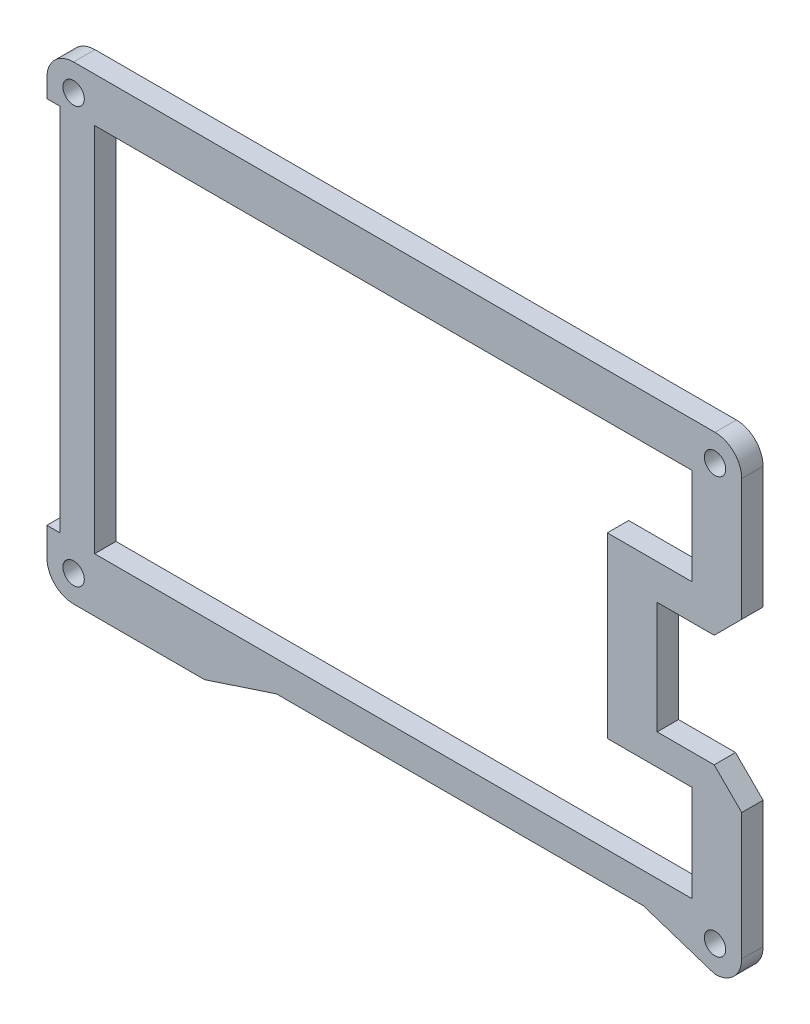
from build123d import *

# Parameters (mm, degrees)
BOSS_EXTRUDE1_DEPTH = 3.048
SKETCH2_R           = 1.355900406
CUT_EXTRUDE1_DEPTH  = 4.048
SKETCH3_R           = 1.524
CUT_EXTRUDE2_DEPTH  = 4.048
CUT_EXTRUDE3_DEPTH  = 4.048
BOSS_EXTRUDE2_DEPTH = 3.048
SKETCH5_W           = 73.1256
SKETCH5_H           = 52.8987
SKETCH5_W_2         = 9.017
SKETCH5_H_2         = 13.74935
CUT_EXTRUDE4_DEPTH  = 4.048
SKETCH6_W           = 3.048
SKETCH6_H           = 13.74935
CUT_EXTRUDE5_DEPTH  = 4.048


with BuildPart() as part:
    # Sketch1 → Boss-Extrude1 (new body)
    with BuildSketch(Plane.XY):
        with BuildLine():
            Line((-309.8086, 128.8851), (-305.87795, 128.8851))
            Line((-305.87795, 128.8851), (-301.9473, 132.81575))
            Line((-301.9473, 132.81575), (-301.9473, 150.9704))
            ThreePointArc((-301.9473, 150.9704), (-303.063223164, 153.664476836), (-305.7573, 154.7804))
            Line((-305.7573, 154.7804), (-397.247125, 154.7804))
            ThreePointArc((-397.247125, 154.7804), (-399.946077222, 153.659592612), (-401.0571, 150.956597849))
            Line((-401.0571, 150.956597849), (-401.0571, 148.341))
            Line((-401.0571, 148.341), (-399.1521, 148.341))
            Line((-399.1521, 148.341), (-399.1521, 95.6449))
            Line((-399.1521, 95.6449), (-401.0571, 95.6449))
            Line((-401.0571, 95.6449), (-401.0571, 91.659304166))
            ThreePointArc((-401.0571, 91.659304166), (-399.951018769, 88.947400452), (-397.2472, 87.8217))
            Line((-397.2472, 87.8217), (-378.5565, 87.8217))
            Line((-378.5565, 87.8217), (-368.3165, 91.1883))
            Line((-368.3165, 91.1883), (-315.9973, 91.1883))
            Line((-315.9973, 91.1883), (-305.7573, 87.8217))
            ThreePointArc((-305.7573, 87.8217), (-303.063223164, 88.937623164), (-301.9473, 91.6317))
            Line((-301.9473, 91.6317), (-301.9473, 111.74645))
            Line((-301.9473, 111.74645), (-305.87795, 115.6771))
            Line((-305.87795, 115.6771), (-309.8086, 115.6771))
            Line((-309.8086, 115.6771), (-314.0123, 115.6771))
            Line((-314.0123, 115.6771), (-314.0123, 128.8851))
            Line((-314.0123, 128.8851), (-309.8086, 128.8851))
        make_face()
        Polygon((-395.3675, 92.9525), (-395.3675, 149.2432), (-309.8086, 149.2432), (-309.8086, 132.81575), (-318.2033, 132.81575), (-318.2033, 111.74645), (-309.8086, 111.74645), (-309.8086, 92.9525), align=None, mode=Mode.SUBTRACT)
    extrude(amount=BOSS_EXTRUDE1_DEPTH)

    # Sketch2 → Cut-Extrude1 (cut, through all)
    with BuildSketch(Plane(origin=(0, 0, 0), x_dir=(-1, 0, 0), z_dir=(0, 0, -1))):
        with Locations((305.7573, 150.9704)):
            Circle(SKETCH2_R)
        with Locations((397.247125, 150.9704)):
            Circle(SKETCH2_R)
        with Locations((397.2472, 91.6317)):
            Circle(SKETCH2_R)
        with Locations((305.7573, 91.6317)):
            Circle(SKETCH2_R)
    extrude(amount=-CUT_EXTRUDE1_DEPTH, mode=Mode.SUBTRACT)

    # Sketch3 → Cut-Extrude2 (cut, through all)
    with BuildSketch(Plane(origin=(0, 0, 0), x_dir=(-1, 0, 0), z_dir=(0, 0, -1))):
        with Locations((305.7573, 150.9704)):
            Circle(SKETCH3_R)
        with Locations((397.247125, 150.9704)):
            Circle(SKETCH3_R)
        with Locations((397.2472, 91.6317)):
            Circle(SKETCH3_R)
        with Locations((305.7573, 91.6317)):
            Circle(SKETCH3_R)
    extrude(amount=-CUT_EXTRUDE2_DEPTH, mode=Mode.SUBTRACT)

    # Sketch4 → Cut-Extrude3 (cut, through all)
    with BuildSketch(Plane.XY.offset(3.048)):
        Polygon((-301.9473, 133.57775), (-305.87795, 129.6471), (-314.0123, 129.6471), (-314.0123, 113.6451), (-305.87795, 113.6451), (-301.9473, 109.71445), align=None)
    extrude(amount=-CUT_EXTRUDE3_DEPTH, mode=Mode.SUBTRACT)

    # Sketch4_4 → Boss-Extrude2 (add)
    with BuildSketch(Plane.XY.offset(3.048)):
        Polygon((-318.2033, 111.74645), (-318.2033, 132.81575), (-309.8086, 132.81575), (-309.8086, 149.2432), (-395.3675, 149.2432), (-395.3675, 92.9525), (-309.8086, 92.9525), (-309.8086, 111.74645), align=None)
    extrude(amount=-BOSS_EXTRUDE2_DEPTH)

    # Sketch5 → Cut-Extrude4 (cut, through all)
    with BuildSketch(Plane.XY.offset(3.048)):
        with Locations((-357.6871, 121.98105)):
            Rectangle(SKETCH5_W, SKETCH5_H)
        with Locations((-316.6158, 141.555725)):
            Rectangle(SKETCH5_W_2, SKETCH5_H_2)
        with Locations((-316.6158, 102.406375)):
            Rectangle(SKETCH5_W_2, SKETCH5_H_2)
    extrude(amount=-CUT_EXTRUDE4_DEPTH, mode=Mode.SUBTRACT)

    # Sketch6 → Cut-Extrude5 (cut, through all)
    with BuildSketch(Plane.XY.offset(3.048)):
        with Locations((-310.5833, 141.555725)):
            Rectangle(SKETCH6_W, SKETCH6_H)
        with Locations((-310.5833, 102.406375)):
            Rectangle(SKETCH6_W, SKETCH6_H)
    extrude(amount=-CUT_EXTRUDE5_DEPTH, mode=Mode.SUBTRACT)


solid = part.part
